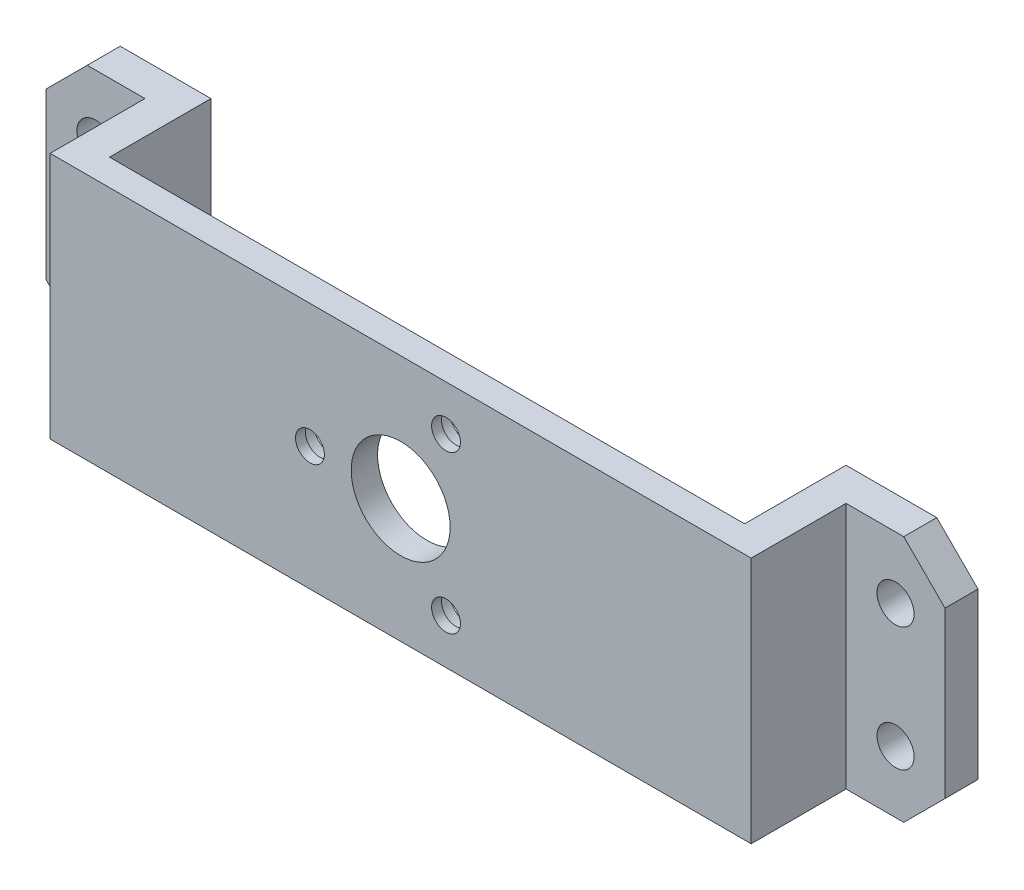
from build123d import *

# Parameters (mm, degrees)
SKETCH1_W           = 85
SKETCH1_H           = 30
SKETCH1_R           = 6
BOSS_EXTRUDE1_DEPTH = 3.2
SKETCH5_R           = 1.75
CUT_EXTRUDE1_DEPTH  = 4.2
SKETCH7_R           = 3
CUT_EXTRUDE2_DEPTH  = 2
SKETCH2_W           = 4
SKETCH2_H           = 30
BOSS_EXTRUDE2_DEPTH = 12.3
SKETCH3_W           = 16
SKETCH3_H           = 30
SKETCH3_R           = 2.25
BOSS_EXTRUDE3_DEPTH = 4
CHAMFER1_SIZE       = 5


with BuildPart() as part:
    # Sketch1 → Boss-Extrude1 (new body)
    with BuildSketch(Plane.XY):
        Rectangle(SKETCH1_W, SKETCH1_H)
        Circle(SKETCH1_R, mode=Mode.SUBTRACT)
    extrude(amount=BOSS_EXTRUDE1_DEPTH)

    # Sketch5 → Cut-Extrude1 (cut, through all)
    with BuildSketch(Plane.XY.offset(3.2)):
        with Locations((5.5, 9.526279442)):
            Circle(SKETCH5_R)
        with Locations((-11, 0)):
            Circle(SKETCH5_R)
        with Locations((5.5, -9.526279442)):
            Circle(SKETCH5_R)
    extrude(amount=-CUT_EXTRUDE1_DEPTH, mode=Mode.SUBTRACT)

    # Sketch7 → Cut-Extrude2 (cut)
    with BuildSketch(Plane(origin=(0, 0, 0), x_dir=(-1, 0, 0), z_dir=(0, 0, -1))):
        with Locations((-5.5, 9.526279442)):
            Circle(SKETCH7_R)
        with Locations((11, 0)):
            Circle(SKETCH7_R)
        with Locations((-5.5, -9.526279442)):
            Circle(SKETCH7_R)
    extrude(amount=-CUT_EXTRUDE2_DEPTH, mode=Mode.SUBTRACT)

    # Sketch2 → Boss-Extrude2 (add)
    with BuildSketch(Plane(origin=(0, 0, 0), x_dir=(-1, 0, 0), z_dir=(0, 0, -1))):
        with Locations((40.5, 0)):
            Rectangle(SKETCH2_W, SKETCH2_H)
        with Locations((-40.5, 0)):
            Rectangle(SKETCH2_W, SKETCH2_H)
    extrude(amount=BOSS_EXTRUDE2_DEPTH)

    # Sketch3 → Boss-Extrude3 (add)
    with BuildSketch(Plane(origin=(0, 0, -12.3), x_dir=(-1, 0, 0), z_dir=(0, 0, -1))):
        with Locations((46.5, 0)):
            Rectangle(SKETCH3_W, SKETCH3_H)
        with Locations((48.5, -7.5)):
            Circle(SKETCH3_R, mode=Mode.SUBTRACT)
        with Locations((48.5, 7.5)):
            Circle(SKETCH3_R, mode=Mode.SUBTRACT)
        with Locations((-46.5, 0)):
            Rectangle(SKETCH3_W, SKETCH3_H)
        with Locations((-48.5, 7.5)):
            Circle(SKETCH3_R, mode=Mode.SUBTRACT)
        with Locations((-48.5, -7.5)):
            Circle(SKETCH3_R, mode=Mode.SUBTRACT)
    extrude(amount=-BOSS_EXTRUDE3_DEPTH)

    # Chamfer1
    chamfer1_edges = [part.edges().sort_by_distance(p)[0] for p in [
        (54.5, 15, -10.3),
        (54.5, -15, -10.3),
        (-54.5, -15, -10.3),
        (-54.5, 15, -10.3),
    ]]
    chamfer(chamfer1_edges, length=CHAMFER1_SIZE)


solid = part.part
